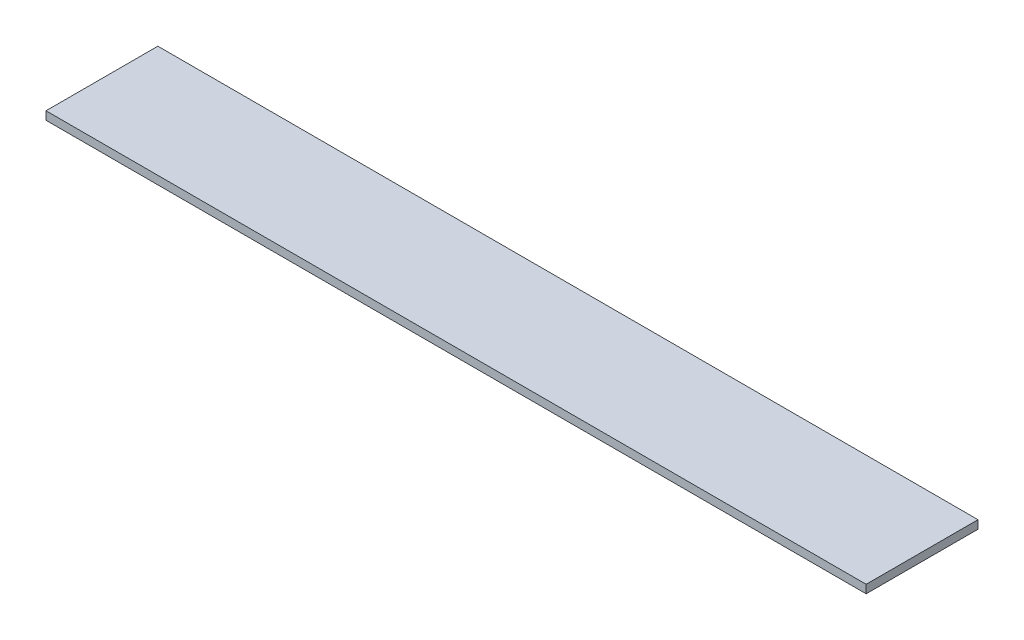
from build123d import *

# Parameters (mm, degrees)
BOSS_EXTRUDE1_DEPTH = 5.6388


with BuildPart() as part:
    # Sketch1 → Boss-Extrude1 (new body)
    with BuildSketch(Plane(origin=(0, 0, 0), x_dir=(1, 0, 0), z_dir=(0, 1, 0))):
        Polygon((-185, -73.025), (373.7224, -73.025), (373.7224, -6.825), (373.7224, 3.175), (175, 3.175), (-175, 3.175), (-185, 3.175), (-185, -6.825), align=None)
    extrude(amount=BOSS_EXTRUDE1_DEPTH)


solid = part.part
